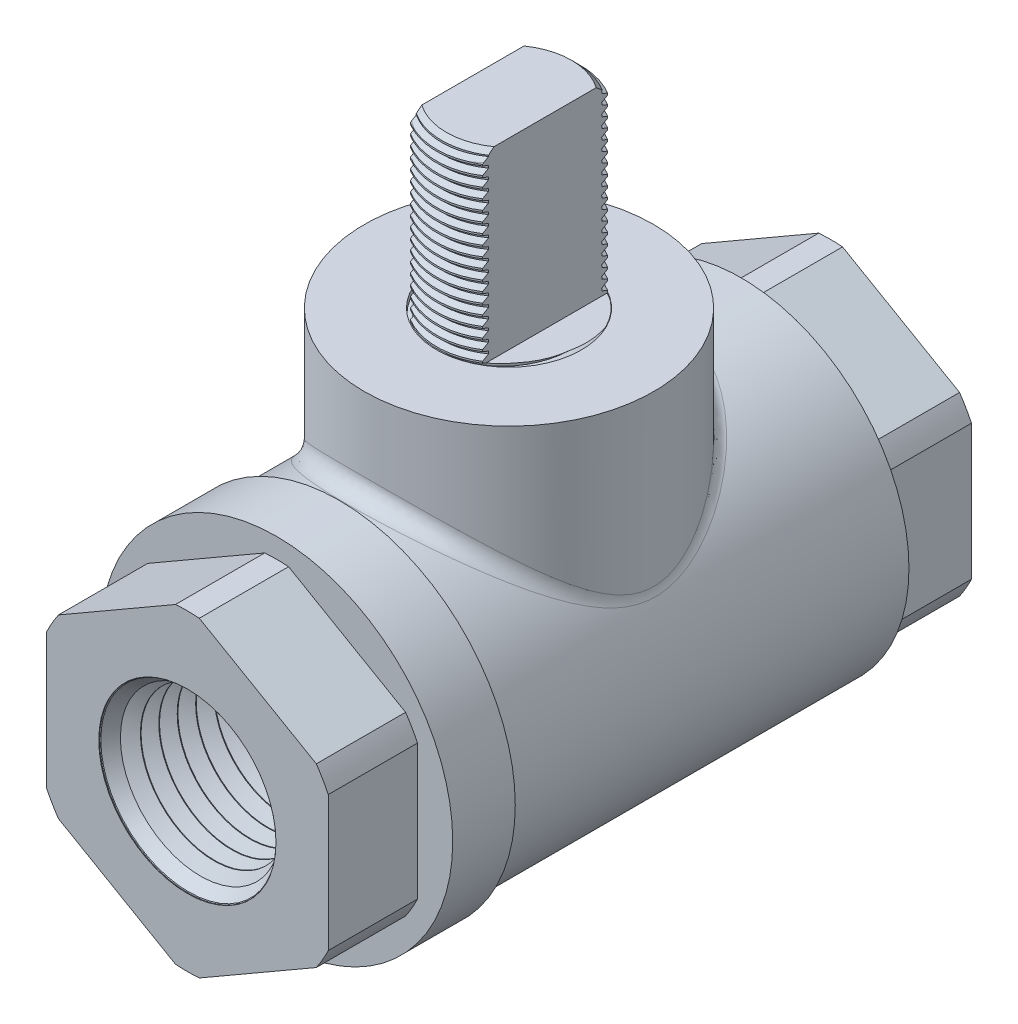
from build123d import *

# Parameters (mm, degrees)
EXTRUDE1_DEPTH       = 50.8
CHAMFER1_SIZE        = 0.762
FILLET5_R            = 1.27
LPATTERN1_COUNT      = 2
LPATTERN1_PITCH      = 0.79375
LPATTERN1_COL_COUNT  = 19
LPATTERN1_COL_PITCH  = 0.79375
SKETCH26_R           = 5.7277
EXTRUDE8_DEPTH       = 0.127
SKETCH16_W           = 7.049911111
SKETCH16_H           = 0.508
SKETCH27_OUTSIDE_W   = 44.952
SKETCH27_OUTSIDE_H   = 67.938
SKETCH27_OUTSIDE_W_2 = 5.7023
SKETCH27_OUTSIDE_H_2 = 11.4046
CUT_EXTRUDE3_DEPTH   = 14.478


with BuildPart() as part:
    # Sketch1 → Revolve1 (revolve)
    with BuildSketch(Plane(origin=(0, -2.929502347, 125.566843264), x_dir=(0, 0, -1), z_dir=(1, 0, 0)), mode=Mode.PRIVATE) as revolve1_sk:
        Polygon((138.978043264, 2.929502347), (138.978043264, 8.376075001), (139.003473261, 8.423481875), (139.619651945, 9.57216882), (139.6734225, 9.573849233), (140.360125233, 8.465879367), (140.413895788, 8.467559781), (141.030074472, 9.616246726), (141.083845027, 9.61792714), (141.770547761, 8.509957274), (141.824318316, 8.511637688), (142.440496999, 9.660324633), (142.494267555, 9.662005047), (143.180970288, 8.554035181), (143.234740843, 8.555715594), (143.850919527, 9.70440254), (143.904690082, 9.706082953), (144.591392816, 8.598113087), (144.645163371, 8.599793501), (145.261342054, 9.748480446), (145.31511261, 9.75016086), (146.001815343, 8.642190994), (146.055585898, 8.643871408), (146.671764582, 9.792558353), (146.725535137, 9.794238767), (147.41223787, 8.686268901), (147.466008426, 8.687949314), (148.082187109, 9.836636259), (148.135957665, 9.838316673), (148.822660398, 8.730346807), (148.876430953, 8.732027221), (149.492609637, 9.880714166), (149.546380192, 9.88239458), (150.233082925, 8.774424714), (150.286853481, 8.776105128), (150.903032164, 9.924792073), (150.956802719, 9.926472487), (151.643505453, 8.818502621), (151.697276008, 8.820183034), (152.313454692, 9.968869979), (152.367225247, 9.970550393), (153.05392798, 8.862580527), (153.107698536, 8.864260941), (153.723877219, 10.012947886), (153.777647774, 10.0146283), (154.464350508, 8.906658434), (154.518121063, 8.908338848), (155.134299747, 10.057025793), (155.188070302, 10.058706207), (155.874773035, 8.95073634), (155.92854359, 8.952416754), (156.544722274, 10.101103699), (156.598492829, 10.102784113), (157.285195563, 8.994814247), (157.338966118, 8.996494661), (157.955144802, 10.145181606), (158.008915357, 10.14686202), (158.69561809, 9.038892154), (158.749388645, 9.040572568), (159.365567329, 10.189259513), (159.419337884, 10.190939926), (160.106040618, 9.08297006), (160.159811173, 9.084650474), (160.159811173, 2.929502347), align=None)
    revolve(revolve1_sk.sketch.rotate(Axis((0, 0, -13.4112), (0, 0, 1)), 90), axis=Axis((0, 0, -13.4112), (0, 0, 1)))

    # Sketch6 → Cut-Revolve3 (revolve, cut)
    with BuildSketch(Plane(origin=(0, 0, 0), x_dir=(0, 0, -1), z_dir=(1, 0, 0)), mode=Mode.PRIVATE) as cut_revolve3_sk:
        Polygon((25.4, 0), (25.4, 6.997283922), (34.592967909, 7.284578526), (34.592967909, 0), align=None)
    revolve(cut_revolve3_sk.sketch.rotate(Axis((0, 0, -34.592967909), (0, 0, 1)), 180), axis=Axis((0, 0, -34.592967909), (0, 0, 1)), mode=Mode.SUBTRACT)

    # Sketch7 → Revolve3 (revolve)
    with BuildSketch(Plane(origin=(0, 0, 0), x_dir=(0, 0, -1), z_dir=(1, 0, 0)), mode=Mode.PRIVATE) as revolve3_sk:
        Polygon((23.622, 5.812288247), (25.4, 6.997283922), (25.4, 5.867853524), align=None)
        Polygon((0, 0), (13.4112, 0), (13.4112, 5.446572654), (13.298627346, 5.334), (0, 5.334), align=None)
    revolve(revolve3_sk.sketch.rotate(Axis((0, 0, -13.4112), (0, 0, -1)), 270), axis=Axis((0, 0, -13.4112), (0, 0, -1)))

    # Mirror2: part across plane


with BuildPart() as part_1:
    add(part.part)
    add(part.part.mirror(Plane.XY))


with BuildPart() as body_2:
    # Sketch8 → Extrude1 (new body)
    with BuildSketch(Plane.XY.offset(25.4)):
        Polygon((0, 12.84627443), (-11.1252, 6.423137215), (-11.1252, -6.423137215), (0, -12.84627443), (11.1252, -6.423137215), (11.1252, 6.423137215), align=None)
    extrude(amount=-EXTRUDE1_DEPTH)

    # Sketch9 → Revolve4 (revolve)
    with BuildSketch(Plane(origin=(0, 0, 0), x_dir=(0, 0, -1), z_dir=(1, 0, 0)), mode=Mode.PRIVATE) as revolve4_sk:
        Polygon((-18.350088889, 6.423137215), (-18.350088889, 13.9065), (-13.4112, 13.9065), (-13.4112, 13.514854728), (-13.134264973, 13.237919701), (18.350088889, 13.237919701), (18.350088889, 6.423137215), align=None)
    revolve(revolve4_sk.sketch.rotate(Axis((0, 0, 0), (0, 0, 1)), 270), axis=Axis((0, 0, 0), (0, 0, 1)))

    # Sketch10 → Revolve5 (revolve)
    with BuildSketch(Plane(origin=(0, 0, 0), x_dir=(0, 0, -1), z_dir=(1, 0, 0))):
        Polygon((0, 1.27), (0, 19.562519701), (5.7277, 19.562519701), (5.7277, 20.349919701), (11.43, 20.349919701), (11.43, 1.27), align=None)
        Polygon((5.7023, 20.349919701), (5.7023, 34.827919701), (0, 34.827919701), (0, 19.587919701), (5.7023, 19.587919701), align=None)
    revolve(axis=Axis((0, 0, 0), (0, 1, 0)))


with BuildPart() as revolve5_piece_1:
    # of the separate pieces the step leaves, piece 1, a body of its own (revolve5_pieces)
    add(body_2.part.solids().sort_by_distance((0, 12.84627443, 25.4))[0])

    # Fillet5
    fillet5_edges = [revolve5_piece_1.edges().sort_by_distance(p)[0] for p in [
        (0, 13.237919708, 11.429999998),
    ]]
    fillet(fillet5_edges, radius=FILLET5_R)



with BuildPart() as revolve5_piece_2:
    # of the separate pieces the step leaves, piece 2, a body of its own (revolve5_pieces)
    add(body_2.part.solids().sort_by_distance((0, 34.827919701, -5.7023))[0])

    # Chamfer1
    chamfer1_edges = [revolve5_piece_2.edges().sort_by_distance(p)[0] for p in [
        (0, 34.827919701, 5.7023),
    ]]
    chamfer(chamfer1_edges, length=CHAMFER1_SIZE)

    # Sketch20 → Cut-Revolve6 (revolve, cut)
    with BuildSketch(Plane(origin=(0, 0, 0), x_dir=(0, 0, -1), z_dir=(1, 0, 0)), mode=Mode.PRIVATE) as cut_revolve6_sk:
        Polygon((5.709188872, 34.728940391), (5.757410974, 34.036085222), (5.311595811, 34.253703807), (5.297818067, 34.451662426), align=None)
    cut_revolve6 = revolve(cut_revolve6_sk.sketch.rotate(Axis((0, 34.827919701, 0.058772234), (0, -0.997586745890785, -0.06943114879529476)), 180), axis=Axis((0, 34.827919701, 0.058772234), (0, -0.997586745890785, -0.06943114879529476)), mode=Mode.SUBTRACT)

    # LPattern1: Cut-Revolve6 ×2
    with Locations(*[(0, i * LPATTERN1_PITCH, 0) for i in range(1, LPATTERN1_COUNT)]):
        add(cut_revolve6, mode=Mode.SUBTRACT)

    # LPattern1 col: Cut-Revolve6 ×19
    with Locations(*[(0, -i * LPATTERN1_COL_PITCH, 0) for i in range(1, LPATTERN1_COL_COUNT)]):
        add(cut_revolve6, mode=Mode.SUBTRACT)


with BuildPart() as revolve5_piece_1_1:
    add(revolve5_piece_1.part)

    add(revolve5_piece_2.part)  # Extrude8 merges Revolve5 piece 2
    # Sketch26 → Extrude8 (add)
    with BuildSketch(Plane(origin=(0, 19.562519701, 0), x_dir=(-1, 0, 0), z_dir=(0, 1, 0))):
        with Locations(Location((0, 0, 0), (0, 0, 270))):
            Circle(SKETCH26_R)
    extrude(amount=EXTRUDE8_DEPTH)

    # Sketch16 → Cut-Revolve5 (revolve, cut)
    with BuildSketch(Plane(origin=(0, 0, 0), x_dir=(0, 0, -1), z_dir=(1, 0, 0)), mode=Mode.PRIVATE) as cut_revolve5_sk:
        with Locations((21.875044445, 12.59227443)):
            Rectangle(SKETCH16_W, SKETCH16_H)
        with Locations((-21.875044445, 12.59227443)):
            Rectangle(SKETCH16_W, SKETCH16_H)
    revolve(cut_revolve5_sk.sketch.rotate(Axis((0, 0, 0), (0, 0, 1)), 270), axis=Axis((0, 0, 0), (0, 0, 1)), mode=Mode.SUBTRACT)

    # Combine1: cut part
    add(part_1.part, mode=Mode.SUBTRACT)

    # Sketch27 outside → Cut-Extrude3 (cut)
    with BuildSketch(Plane(origin=(0, 34.827919701, 0), x_dir=(-1, 0, 0), z_dir=(0, 1, 0))):
        Rectangle(SKETCH27_OUTSIDE_W, SKETCH27_OUTSIDE_H)
        Rectangle(SKETCH27_OUTSIDE_W_2, SKETCH27_OUTSIDE_H_2, mode=Mode.SUBTRACT)
    extrude(amount=-CUT_EXTRUDE3_DEPTH, mode=Mode.SUBTRACT)


solid = revolve5_piece_1_1.part
